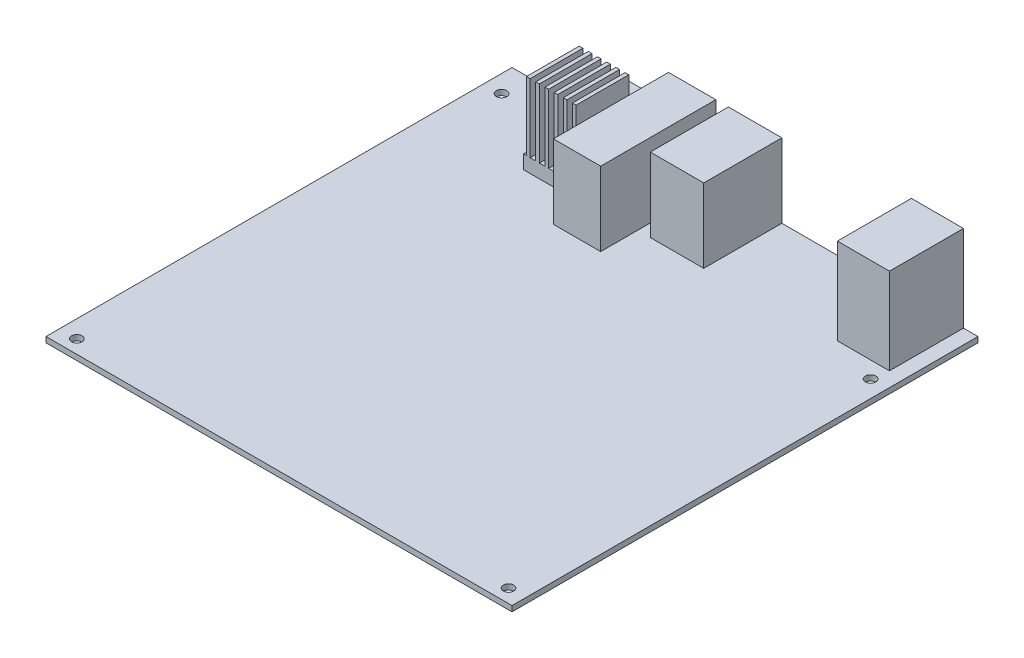
from build123d import *

# Parameters (mm, degrees)
SKETCH1_W                = 170
SKETCH1_H                = 170
BOSS_EXTRUDE1_DEPTH      = 2
F_6_CLEARANCE_HOLE1_D    = 3.7973
SKETCH5_W                = 19
SKETCH5_H                = 27
BOSS_EXTRUDE2_DEPTH      = 31.5
SKETCH6_W                = 19.5
SKETCH6_H                = 28.5
SKETCH6_W_2              = 17.25
SKETCH6_H_2              = 42
BOSS_EXTRUDE3_DEPTH      = 27
SKETCH7_W                = 19.2
SKETCH7_H                = 19.2
BOSS_EXTRUDE4_DEPTH      = 30
SKETCH8_W                = 2
SKETCH8_H                = 25
SKETCH8_W_2              = 1.1
CUT_EXTRUDE1_DEPTH       = 160
SKETCH9_W                = 31
SKETCH9_H                = 11
BOSS_EXTRUDE5_DEPTH      = 6
BOSS_EXTRUDE5_DEPTH_BACK = 4.2


with BuildPart() as part:
    # Sketch1 → Boss-Extrude1 (new body)
    with BuildSketch(Plane(origin=(0, 0, 0), x_dir=(1, 0, 0), z_dir=(0, 1, 0))):
        Rectangle(SKETCH1_W, SKETCH1_H)
    extrude(amount=BOSS_EXTRUDE1_DEPTH)

    # #6 Clearance Hole1 (through all)
    with Locations(Plane(origin=(-78.65, 2, -74.84), x_dir=(0, 0, 1), z_dir=(0, 1, 0))):
        with Locations((0, 0), (154.94, 0), (154.94, 157.48), (22.86, 157.48)):
            Hole(F_6_CLEARANCE_HOLE1_D / 2)

    # Sketch5 → Boss-Extrude2 (add)
    with BuildSketch(Plane(origin=(0, 2, 0), x_dir=(1, 0, 0), z_dir=(0, 1, 0))):
        with Locations((70.2, 71.5)):
            Rectangle(SKETCH5_W, SKETCH5_H)
    extrude(amount=BOSS_EXTRUDE2_DEPTH)

    # Sketch6 → Boss-Extrude3 (add)
    with BuildSketch(Plane(origin=(0, 2, 0), x_dir=(1, 0, 0), z_dir=(0, 1, 0))):
        with Locations((3.7, 70.75)):
            Rectangle(SKETCH6_W, SKETCH6_H)
        with Locations((-19.275, 64)):
            Rectangle(SKETCH6_W_2, SKETCH6_H_2)
    extrude(amount=BOSS_EXTRUDE3_DEPTH)

    # Sketch7 → Boss-Extrude4 (add)
    with BuildSketch(Plane(origin=(0, 2, 0), x_dir=(1, 0, 0), z_dir=(0, 1, 0))):
        with Locations((-41, 64.4)):
            Rectangle(SKETCH7_W, SKETCH7_H)
    extrude(amount=BOSS_EXTRUDE4_DEPTH)

    # Sketch8 → Cut-Extrude1 (cut, through all)
    with BuildSketch(Plane(origin=(0, 0, -74), x_dir=(-1, 0, 0), z_dir=(0, 0, -1))):
        with Locations((33.75, 19.5)):
            Rectangle(SKETCH8_W, SKETCH8_H)
        with Locations((37.1, 19.5)):
            Rectangle(SKETCH8_W, SKETCH8_H)
        with Locations((50.05, 19.5)):
            Rectangle(SKETCH8_W_2, SKETCH8_H)
        with Locations((40.45, 19.5)):
            Rectangle(SKETCH8_W, SKETCH8_H)
        with Locations((47.15, 19.5)):
            Rectangle(SKETCH8_W, SKETCH8_H)
        with Locations((43.8, 19.5)):
            Rectangle(SKETCH8_W, SKETCH8_H)
    extrude(amount=-CUT_EXTRUDE1_DEPTH, mode=Mode.SUBTRACT)

    # Sketch9 → Boss-Extrude5 (add, two sides)
    with BuildSketch(Plane(origin=(0, 0, -85), x_dir=(-1, 0, 0), z_dir=(0, 0, -1))) as boss_extrude5_sk:
        with Locations((47.9, 7.5)):
            Rectangle(SKETCH9_W, SKETCH9_H)
    extrude(amount=BOSS_EXTRUDE5_DEPTH)
    extrude(boss_extrude5_sk.sketch, amount=-BOSS_EXTRUDE5_DEPTH_BACK)


solid = part.part
